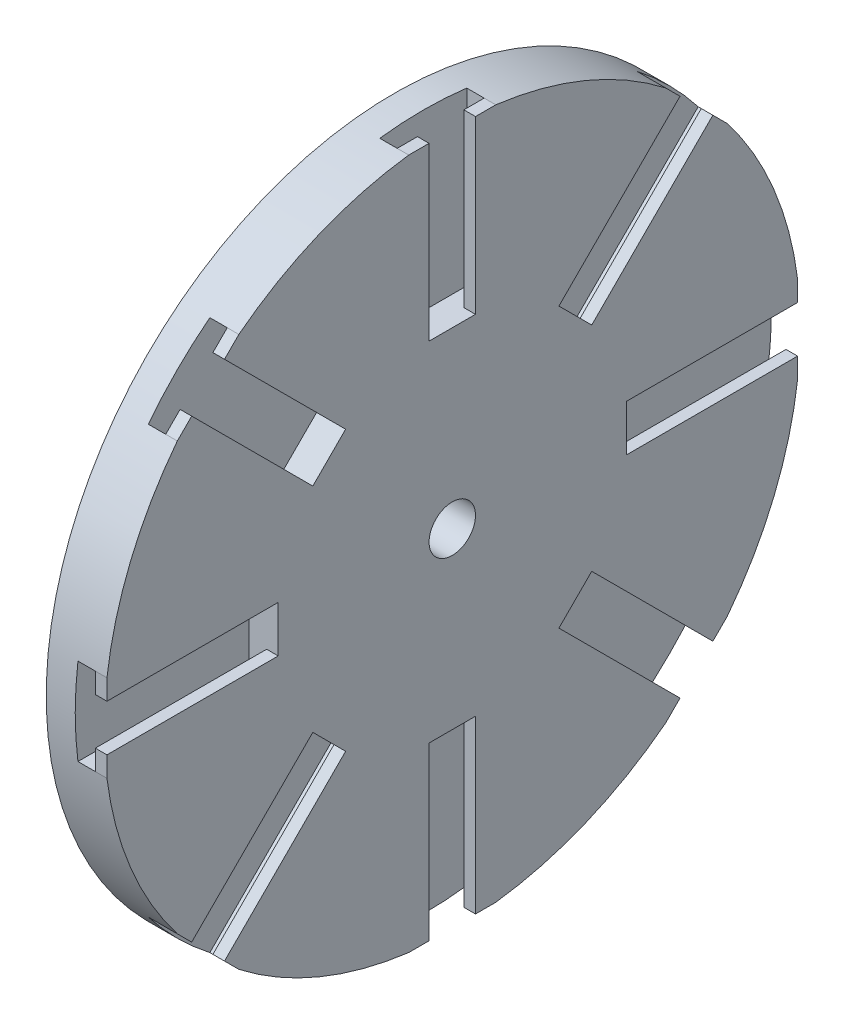
from build123d import *

# Parameters (mm, degrees)
SKETCH2_W           = 15
SKETCH2_H           = 30
SKETCH2_W_2         = 30
SKETCH2_H_2         = 15
CUT_EXTRUDE1_DEPTH  = 5
SKETCH3_W           = 29.529404499
SKETCH3_H           = 3.5
SKETCH3_W_2         = 3.5
SKETCH3_H_2         = 29.529404499
BOSS_EXTRUDE1_DEPTH = 2


with BuildPart() as part:
    # Sketch1 → Revolve2 (revolve)
    with BuildSketch(Plane.XY):
        Polygon((0, 4), (0, 60), (-10, 60), (-10, 15), (-25, 15), (-25, 4), align=None)
    revolve(axis=Axis((0, 0, 0), (-1, 0, 0)))

    # Sketch2 → Cut-Extrude1 (cut)
    with BuildSketch(Plane(origin=(0, 0, 0), x_dir=(0, 0, -1), z_dir=(1, 0, 0))):
        Polygon((15.909902577, 26.516504294), (37.123106012, 47.72970773), (47.72970773, 37.123106012), (26.516504294, 15.909902577), align=None)
        with Locations((0, 45)):
            Rectangle(SKETCH2_W, SKETCH2_H)
        with Locations((45, 0)):
            Rectangle(SKETCH2_W_2, SKETCH2_H_2)
        Polygon((26.516504295, -15.909902577), (47.72970773, -37.123106012), (37.123106012, -47.72970773), (15.909902577, -26.516504294), align=None)
        with Locations((0, -45)):
            Rectangle(SKETCH2_W, SKETCH2_H)
        Polygon((-15.909902577, -26.516504294), (-37.123106012, -47.72970773), (-47.72970773, -37.123106012), (-26.516504294, -15.909902577), align=None)
        with Locations((-45, 0)):
            Rectangle(SKETCH2_W_2, SKETCH2_H_2)
        Polygon((-26.516504294, 15.909902577), (-47.72970773, 37.123106012), (-37.123106012, 47.72970773), (-15.909902577, 26.516504294), align=None)
    extrude(amount=-CUT_EXTRUDE1_DEPTH, mode=Mode.SUBTRACT)

    # Sketch3 → Boss-Extrude1 (add)
    with BuildSketch(Plane(origin=(0, 0, 0), x_dir=(0, 0, -1), z_dir=(1, 0, 0))):
        Polygon((-15.909902577, 26.516504294), (-36.790344742, 47.39694646), (-39.265218476, 44.922072726), (-18.384776311, 24.04163056), align=None)
        Polygon((-24.04163056, 18.384776311), (-44.922072726, 39.265218476), (-47.39694646, 36.790344742), (-26.516504294, 15.909902577), align=None)
        with Locations((-44.76470225, 5.75)):
            Rectangle(SKETCH3_W, SKETCH3_H)
        with Locations((-44.76470225, -5.75)):
            Rectangle(SKETCH3_W, SKETCH3_H)
        Polygon((-26.516504294, -15.909902577), (-47.39694646, -36.790344742), (-44.922072726, -39.265218476), (-24.04163056, -18.384776311), align=None)
        Polygon((-18.384776311, -24.04163056), (-39.265218476, -44.922072726), (-36.790344742, -47.39694646), (-15.909902577, -26.516504294), align=None)
        with Locations((-5.75, -44.76470225)):
            Rectangle(SKETCH3_W_2, SKETCH3_H_2)
        with Locations((5.75, -44.76470225)):
            Rectangle(SKETCH3_W_2, SKETCH3_H_2)
        Polygon((36.790344742, -47.39694646), (39.265218476, -44.922072726), (18.384776311, -24.04163056), (15.909902577, -26.516504294), align=None)
        Polygon((44.922072726, -39.265218476), (47.39694646, -36.790344742), (26.516504295, -15.909902577), (24.04163056, -18.384776311), align=None)
        with Locations((44.76470225, -5.75)):
            Rectangle(SKETCH3_W, SKETCH3_H)
        with Locations((44.76470225, 5.75)):
            Rectangle(SKETCH3_W, SKETCH3_H)
        Polygon((47.39694646, 36.790344742), (44.922072726, 39.265218476), (24.04163056, 18.384776311), (26.516504294, 15.909902577), align=None)
        Polygon((39.265218476, 44.922072726), (36.790344742, 47.39694646), (15.909902577, 26.516504294), (18.384776311, 24.04163056), align=None)
        with Locations((5.75, 44.76470225)):
            Rectangle(SKETCH3_W_2, SKETCH3_H_2)
        with Locations((-5.75, 44.76470225)):
            Rectangle(SKETCH3_W_2, SKETCH3_H_2)
    extrude(amount=-BOSS_EXTRUDE1_DEPTH)


solid = part.part
